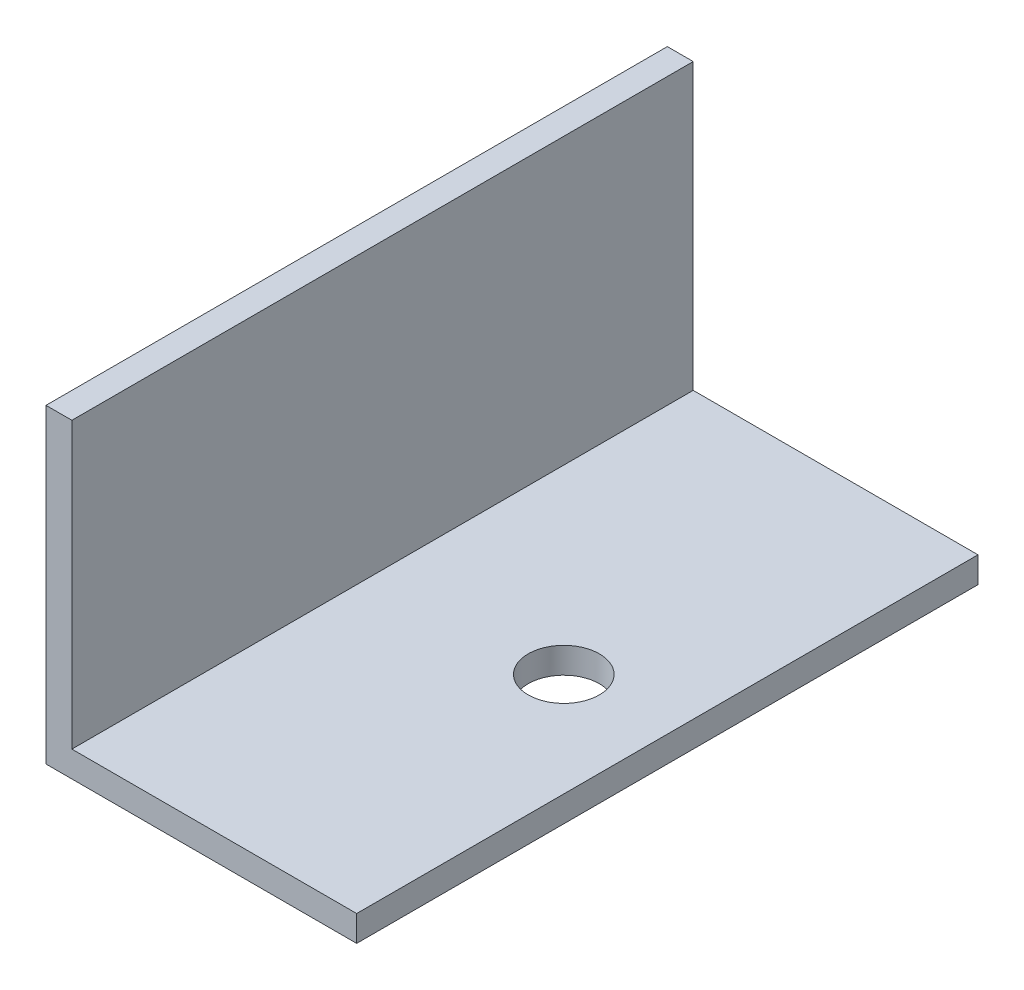
from build123d import *

# Parameters (mm, degrees)
BOSS_EXTRUDE1_DEPTH = 38.1
CUT_EXTRUDE1_REACH  = 5.175
SKETCH3_R           = 4.365625


with BuildPart() as part:
    # Sketch1 → Boss-Extrude1 (new body, symmetric)
    with BuildSketch(Plane(origin=(0, 0, 0), x_dir=(-1, 0, 0), z_dir=(0, 0, 1))):
        Polygon((0, 0), (-38.1, 0), (-38.1, -3.175), (-3.175, -3.175), (-3.175, -38.1), (0, -38.1), align=None)
    extrude(amount=BOSS_EXTRUDE1_DEPTH, both=True)

    # Sketch3 → Cut-Extrude1 (cut, up to next)
    with BuildSketch(Plane(origin=(0, 3.175, 0), x_dir=(1, 0, 0), z_dir=(0, 1, 0)), mode=Mode.PRIVATE) as cut_extrude1_sk1:
        with Locations(Location((25.4, 0, 0), (0, 0, 270))):  # turned: the seam where the file's is
            Circle(SKETCH3_R)
    cut_extrude1_tool1 = extrude(cut_extrude1_sk1.sketch, amount=-CUT_EXTRUDE1_REACH, mode=Mode.PRIVATE) & part.part
    add(cut_extrude1_tool1.solids().sort_by_distance((25.4, 3.175, 0))[0], mode=Mode.SUBTRACT)


solid = part.part
